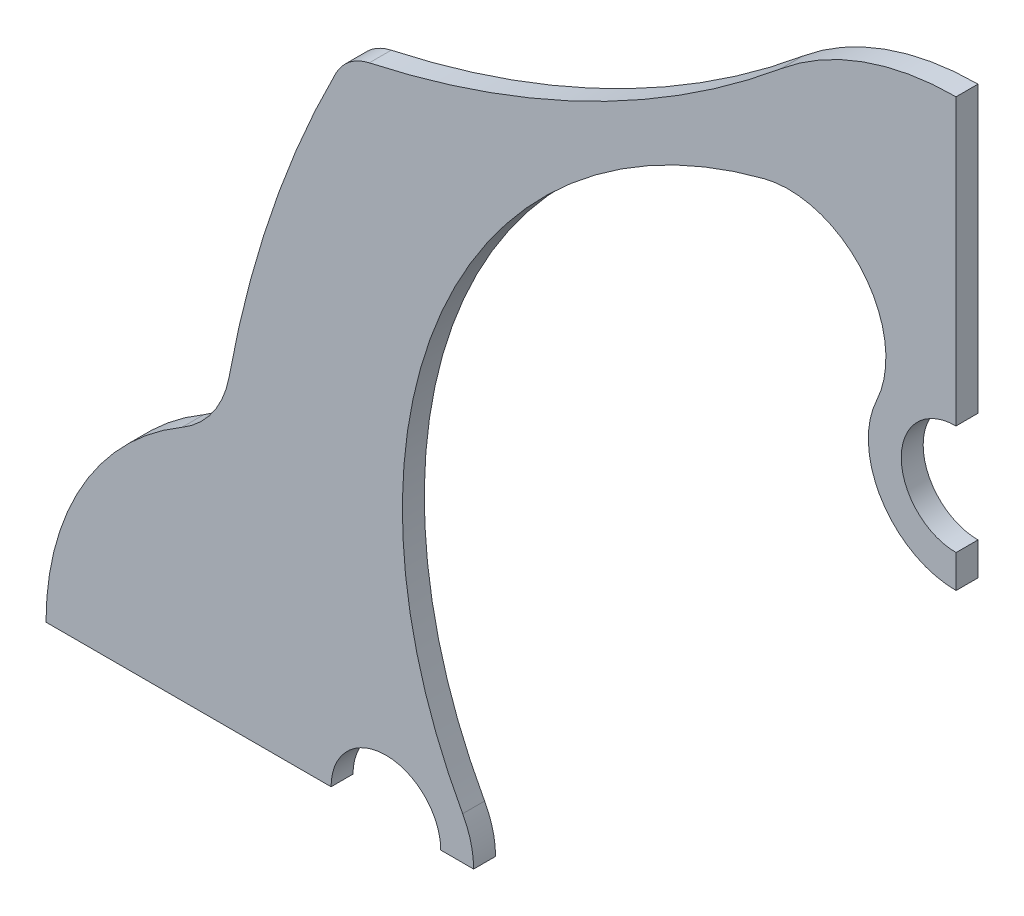
from build123d import *

# Parameters (mm, degrees)
LINEAR_AUSTRAGEN1_DEPTH = 1


with BuildPart() as part:
    # Außenkontur → Linear austragen1 (new body, symmetric)
    with BuildSketch(Plane.XY):
        with BuildLine():
            Line((-83, 0), (-57, 0))
            ThreePointArc((-57, 0), (-52, 5), (-47, 0))
            Line((-47, 0), (-44, 0))
            ThreePointArc((-44, 0), (-44.254033308, 2), (-45, 3.872983346))
            ThreePointArc((-45, 3.872983346), (-46.916580756, 42.566918881), (-17.5, 67.777208559))
            ThreePointArc((-17.5, 67.777208559), (-8.441984355, 64.845892989), (-7.240867658, 55.401446097))
            ThreePointArc((-7.240867658, 55.401446097), (-6.75320549, 47.711152181), (0, 44))
            Line((0, 44), (0, 47))
            ThreePointArc((0, 47), (-5, 52), (0, 57))
            Line((0, 57), (0, 83))
            ThreePointArc((0, 83), (-8.493750568, 81.512894362), (-15.977012787, 77.228496103))
            ThreePointArc((-15.977012787, 77.228496103), (-33.644463337, 65.816474944), (-53.515303741, 58.922801215))
            ThreePointArc((-53.515303741, 58.922801215), (-55.306825995, 58.089224466), (-56.568542495, 56.568542495))
            ThreePointArc((-56.568542495, 56.568542495), (-62.483030705, 42.514608), (-66.293095094, 27.75054166))
            ThreePointArc((-66.293095094, 27.75054166), (-67.776085308, 24.196284331), (-70.608999234, 21.587337453))
            ThreePointArc((-70.608999234, 21.587337453), (-79.682077632, 12.445381054), (-83, 0))
        make_face()
    extrude(amount=LINEAR_AUSTRAGEN1_DEPTH, both=True)


solid = part.part
